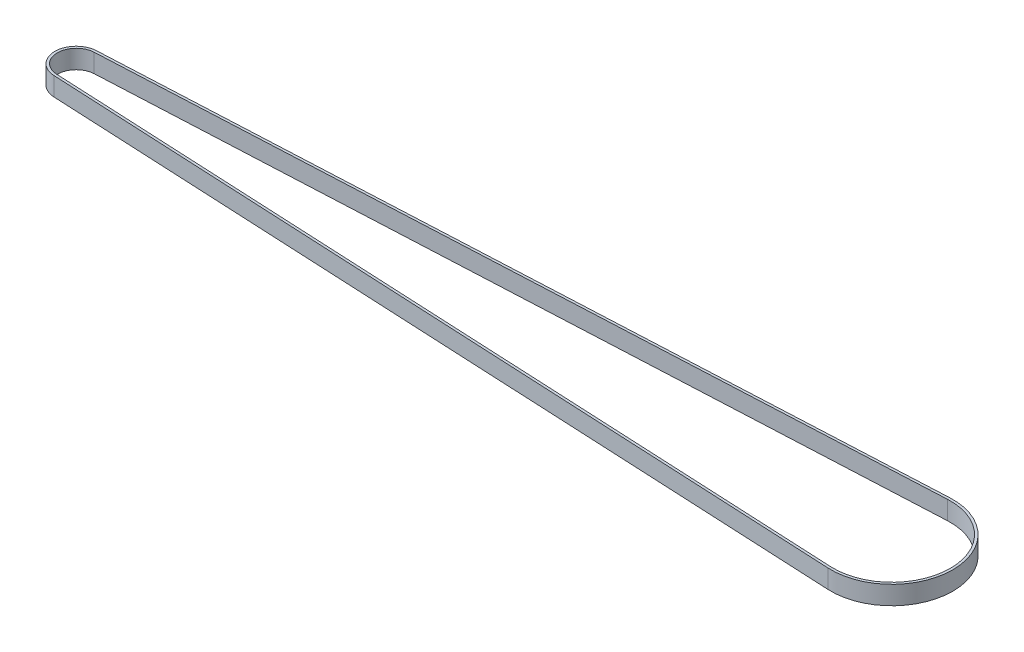
from build123d import *

# Parameters (mm, degrees)
BOSS_EXTRUDE1_DEPTH = 6


with BuildPart() as part:
    # Sketch1 → Boss-Extrude1 (new body)
    with BuildSketch(Plane(origin=(0, 0, 0), x_dir=(1, 0, 0), z_dir=(0, 1, 0))):
        with BuildLine():
            Line((-0.334505703, -6.891886965), (262.047385932, -19.626895486))
            ThreePointArc((262.047385932, -19.626895486), (282.65, 0), (262.047385932, 19.626895486))
            Line((262.047385932, 19.626895486), (-0.334505703, 6.891886965))
            ThreePointArc((-0.334505703, 6.891886965), (-6.9, 0), (-0.334505703, -6.891886965))
        make_face()
        with BuildLine():
            Line((-0.295722433, 6.092827606), (262.086169202, 18.827836128))
            ThreePointArc((262.086169202, 18.827836128), (281.85, 0), (262.086169202, -18.827836128))
            Line((262.086169202, -18.827836128), (-0.295722433, -6.092827606))
            ThreePointArc((-0.295722433, -6.092827606), (-6.1, 0), (-0.295722433, 6.092827606))
        make_face(mode=Mode.SUBTRACT)
    extrude(amount=BOSS_EXTRUDE1_DEPTH)


solid = part.part
